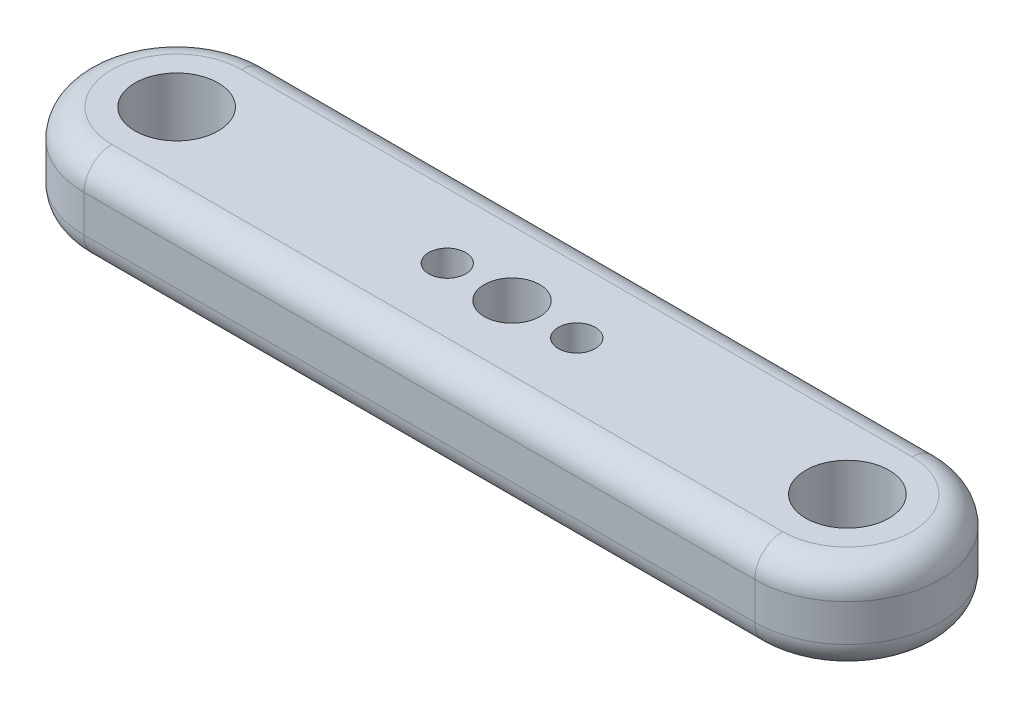
from build123d import *

# Parameters (mm, degrees)
SKETCH2_R           = 5
BOSS_EXTRUDE1_DEPTH = 10
FILLET1_R           = 3
BOSS_EXTRUDE2_DEPTH = 10
SKETCH5_R           = 5
SKETCH5_R_2         = 4.5
BOSS_EXTRUDE3_DEPTH = 10
SKETCH6_R           = 2
CUT_EXTRUDE1_DEPTH  = 10
SKETCH7_R           = 3
CUT_EXTRUDE2_DEPTH  = 10


with BuildPart() as part:
    # Sketch2 → Boss-Extrude1 (new body)
    with BuildSketch(Plane(origin=(0, 0, 0), x_dir=(1, 0, 0), z_dir=(0, 1, 0))):
        with BuildLine():
            Line((36.25, 10), (-36.25, 10))
            ThreePointArc((-36.25, 10), (-46.25, 0), (-36.25, -10))
            Line((-36.25, -10), (36.25, -10))
            ThreePointArc((36.25, -10), (46.25, 0), (36.25, 10))
        make_face()
        with Locations((-36.25, 0)):
            Circle(SKETCH2_R, mode=Mode.SUBTRACT)
        with BuildLine():
            ThreePointArc((5, 0), (3.535533906, -3.535533906), (0, -5))
            ThreePointArc((0, -5), (-5, 0), (0, 5))
            ThreePointArc((0, 5), (3.535533906, 3.535533906), (5, 0))
        make_face(mode=Mode.SUBTRACT)
        with Locations((36.25, 0)):
            Circle(SKETCH2_R, mode=Mode.SUBTRACT)
    extrude(amount=BOSS_EXTRUDE1_DEPTH)

    # Fillet1
    fillet1_edges = [part.edges().sort_by_distance(p)[0] for p in [
        (46.25, 0, 0),
        (0, 0, 10),
        (0, 10, 10),
        (46.25, 10, 0),
        (0, 10, -10),
        (-46.25, 10, 0),
        (-46.25, 0, 0),
        (0, 0, -10),
    ]]
    fillet(fillet1_edges, radius=FILLET1_R)

    # Sketch3 → Boss-Extrude2 (add)
    with BuildSketch(Plane(origin=(0, 10, 0), x_dir=(1, 0, 0), z_dir=(0, 1, 0))):
        with BuildLine():
            Line((5, 0), (0, 0))
            Line((0, 0), (-5, 0))
            ThreePointArc((-5, 0), (0, -5), (5, 0))
        make_face()
        with BuildLine():
            Line((-5, 0), (0, 0))
            Line((0, 0), (5, 0))
            ThreePointArc((5, 0), (0, 5), (-5, 0))
        make_face()
    extrude(amount=-BOSS_EXTRUDE2_DEPTH)

    # Sketch5 → Boss-Extrude3 (add)
    with BuildSketch(Plane(origin=(0, 10, 0), x_dir=(1, 0, 0), z_dir=(0, 1, 0))):
        with Locations((-36.25, 0)):
            Circle(SKETCH5_R)
        with Locations((-36.25, 0)):
            Circle(SKETCH5_R_2, mode=Mode.SUBTRACT)
        with Locations((36.25, 0)):
            Circle(SKETCH5_R)
        with Locations((36.25, 0)):
            Circle(SKETCH5_R_2, mode=Mode.SUBTRACT)
    extrude(amount=-BOSS_EXTRUDE3_DEPTH)

    # Sketch6 → Cut-Extrude1 (cut)
    with BuildSketch(Plane(origin=(0, 10, 0), x_dir=(1, 0, 0), z_dir=(0, 1, 0))):
        with Locations((-7, 0)):
            Circle(SKETCH6_R)
        with Locations((7, 0)):
            Circle(SKETCH6_R)
    extrude(amount=-CUT_EXTRUDE1_DEPTH, mode=Mode.SUBTRACT)

    # Sketch7 → Cut-Extrude2 (cut)
    with BuildSketch(Plane(origin=(0, 10, 0), x_dir=(1, 0, 0), z_dir=(0, 1, 0))):
        Circle(SKETCH7_R)
    extrude(amount=-CUT_EXTRUDE2_DEPTH, mode=Mode.SUBTRACT)


solid = part.part
